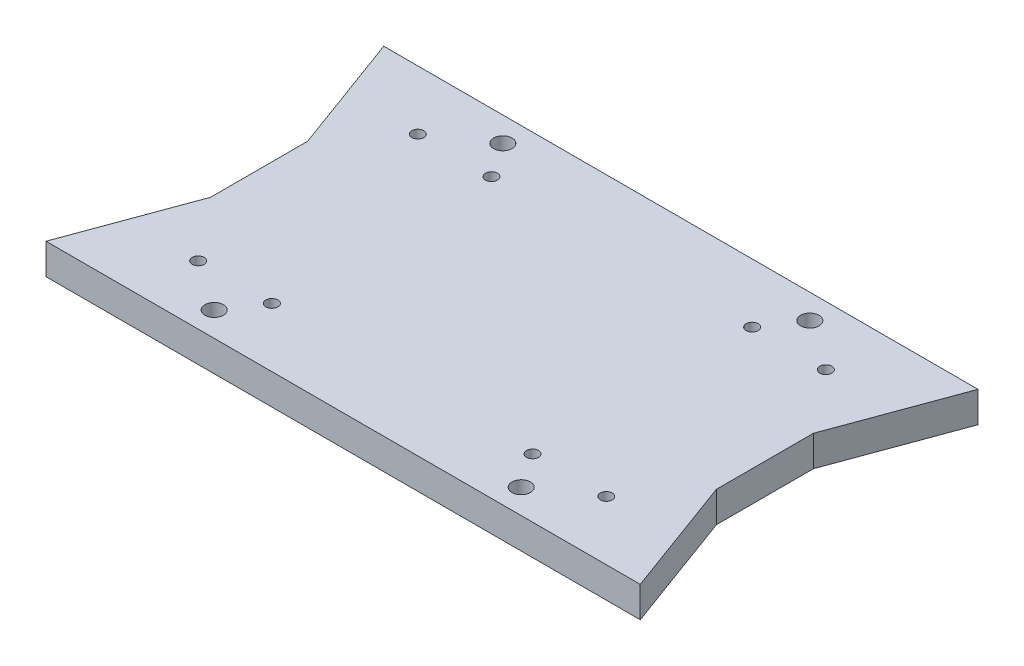
from build123d import *

# Parameters (mm, degrees)
SKETCH10_R          = 1.905
BOSS_EXTRUDE2_DEPTH = 6.35
SKETCH11_R          = 1.2446
CUT_EXTRUDE1_DEPTH  = 6.35


with BuildPart() as part:
    # Sketch10 → Boss-Extrude2 (new body)
    with BuildSketch(Plane(origin=(0, 0, 0), x_dir=(1, 0, 0), z_dir=(0, 1, 0))):
        Polygon((0, 69.85), (9.144, 44.958), (9.144, 24.894999994), (0, 0), (61.443008686, 0), (61.443008686, 69.85), align=None)
        with Locations((29.693008686, 64.77)):
            Circle(SKETCH10_R, mode=Mode.SUBTRACT)
        with Locations((29.693008686, 5.08)):
            Circle(SKETCH10_R, mode=Mode.SUBTRACT)
    boss_extrude2 = extrude(amount=BOSS_EXTRUDE2_DEPTH)

    # Sketch11 → Cut-Extrude1 (cut)
    with BuildSketch(Plane(origin=(0, 6.35, 0), x_dir=(1, 0, 0), z_dir=(0, 1, 0))):
        with Locations((34.490278238, 57.62800006)):
            Circle(SKETCH11_R)
        with Locations((19.250278238, 57.62800006)):
            Circle(SKETCH11_R)
        with Locations((34.490278238, 12.224999934)):
            Circle(SKETCH11_R)
        with Locations((19.250278238, 12.224999934)):
            Circle(SKETCH11_R)
    cut_extrude1 = extrude(amount=-CUT_EXTRUDE1_DEPTH, mode=Mode.SUBTRACT)

    # Mirror3: Boss-Extrude2, Cut-Extrude1 across plane
    add(boss_extrude2.mirror(Plane(origin=(61.443008686, 6.35, 0), x_dir=(0, 0, 1), z_dir=(-1, 0, 0))))
    add(cut_extrude1.mirror(Plane(origin=(61.443008686, 6.35, 0), x_dir=(0, 0, 1), z_dir=(-1, 0, 0))), mode=Mode.SUBTRACT)


solid = part.part
